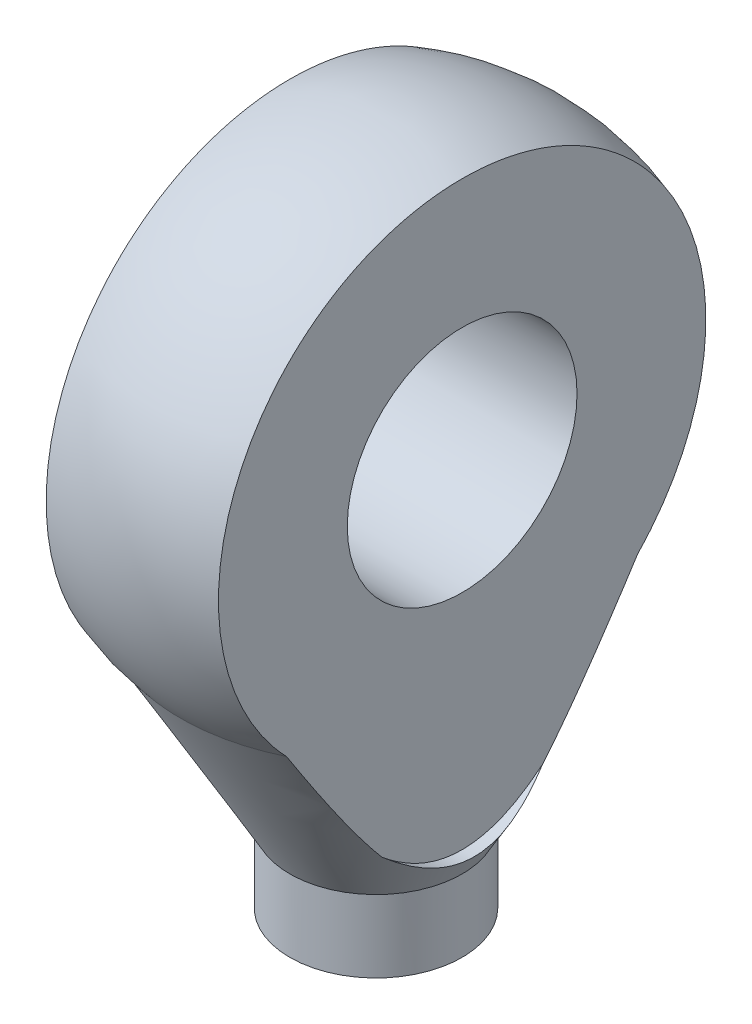
from build123d import *

# Parameters (mm, degrees)
SZKIC2_W                   = 5.611911117
SZKIC2_H                   = 18
WYTNIJ_WYCI_GNI_CIE3_DEPTH = 100
SZKIC3_R                   = 4
WYTNIJ_WYCI_GNI_CIE4_DEPTH = 9
WYTNIJ_WYCI_GNI_CIE5_DEPTH = 1
SZKIC5_R                   = 4
WYTNIJ_WYCI_GNI_CIE6_DEPTH = 70


with BuildPart() as part:
    # Szkic1 → Obrót1 (revolve)
    with BuildSketch(Plane.XY):
        with BuildLine():
            Line((0, 0), (-2, 0))
            Line((-2, 0), (-2, 47.515991356))
            Line((-2, 47.515991356), (-4, 47.515991356))
            Line((-4, 47.515991356), (-4, 52.515991356))
            Line((-4, 52.515991356), (-3, 52.515991356))
            Line((-3, 52.515991356), (-3, 72.515991356))
            Line((-3, 72.515991356), (-6.811196546, 79.117177411))
            ThreePointArc((-6.811196546, 79.117177411), (-8.18368509, 88.745303506), (0, 94))
            Line((0, 94), (0, 87.5))
            ThreePointArc((0, 87.5), (-2.5, 85), (0, 82.5))
            Line((0, 82.5), (0, 0))
        make_face()
    revolve(axis=Axis((0, 82.5, 0), (0, -1, 0)))

    # Szkic2 → Wytnij-wyciągnięcie3 (cut)
    with BuildSketch(Plane(origin=(0, 0, 0), x_dir=(1, 0, 0), z_dir=(0, 1, 0))):
        with Locations((-6.805955559, 0)):
            Rectangle(SZKIC2_W, SZKIC2_H)
        with Locations((6.805955559, 0)):
            Rectangle(SZKIC2_W, SZKIC2_H)
    extrude(amount=WYTNIJ_WYCI_GNI_CIE3_DEPTH, mode=Mode.SUBTRACT)

    # Szkic3 → Wytnij-wyciągnięcie4 (cut, through all)
    with BuildSketch(Plane.ZY.offset(4)):
        with Locations((0, 85)):
            Circle(SZKIC3_R)
    extrude(amount=-WYTNIJ_WYCI_GNI_CIE4_DEPTH, mode=Mode.SUBTRACT)

    # Szkic4 → Wytnij-wyciągnięcie5 (cut)
    with BuildSketch(Plane.ZY.offset(4)):
        with BuildLine():
            ThreePointArc((6.270693727, 78.457606273), (-1.54e-07, 94.062257748), (-6.270693505, 78.45760606))
            add(Edge.make_bspline(
                [(-6.270693505, 78.45760606), (-5.860155238, 77.884005031), (-5.439822901, 77.318273551), (-4.56334323, 76.215587996), (-4.106381954, 75.67754923), (-3.363374021, 74.922329572), (-3.10680463, 74.680734677), (-2.565651322, 74.22947798), (-2.278481074, 74.018621845), (-1.674076312, 73.65846472), (-1.356546022, 73.509032989), (-0.676664628, 73.299784881), (-0.328815369, 73.245372297), (0.202925796, 73.249526844), (0.380729476, 73.265518373), (0.727839454, 73.323535586), (0.898553898, 73.365855519), (1.234860958, 73.474497232), (1.400715996, 73.541171917), (1.719331355, 73.691591375), (1.873358854, 73.775663717), (2.32266111, 74.049331959), (2.606912587, 74.261443159), (3.145505929, 74.716004998), (3.399015103, 74.956985507), (4.130320647, 75.70528438), (4.580547786, 76.236525924), (5.447234702, 77.328310614), (5.863652605, 77.888890096), (6.270693727, 78.457606273)],
                knots=[0, 0, 0, 0, 0.125, 0.125, 0.25, 0.25, 0.3125, 0.3125, 0.375, 0.375, 0.4375, 0.4375, 0.5, 0.5, 0.53125, 0.53125, 0.5625, 0.5625, 0.59375, 0.59375, 0.625, 0.625, 0.6875, 0.6875, 0.75, 0.75, 0.875, 0.875, 1, 1, 1, 1], degree=3))
        make_face()
    wytnij_wyci_gni_cie5 = extrude(amount=-WYTNIJ_WYCI_GNI_CIE5_DEPTH, mode=Mode.SUBTRACT)

    # Lustro1: Wytnij-wyciągnięcie5 across plane
    add(wytnij_wyci_gni_cie5.mirror(Plane(origin=(0, 0, 0), x_dir=(0, 0, 1), z_dir=(1, 0, 0))), mode=Mode.SUBTRACT)

    # Szkic5 → Wytnij-wyciągnięcie6 (cut)
    with BuildSketch(Plane(origin=(0, 0, 0), x_dir=(1, 0, 0), z_dir=(0, 1, 0))):
        Circle(SZKIC5_R)
    extrude(amount=WYTNIJ_WYCI_GNI_CIE6_DEPTH, mode=Mode.SUBTRACT)


solid = part.part
